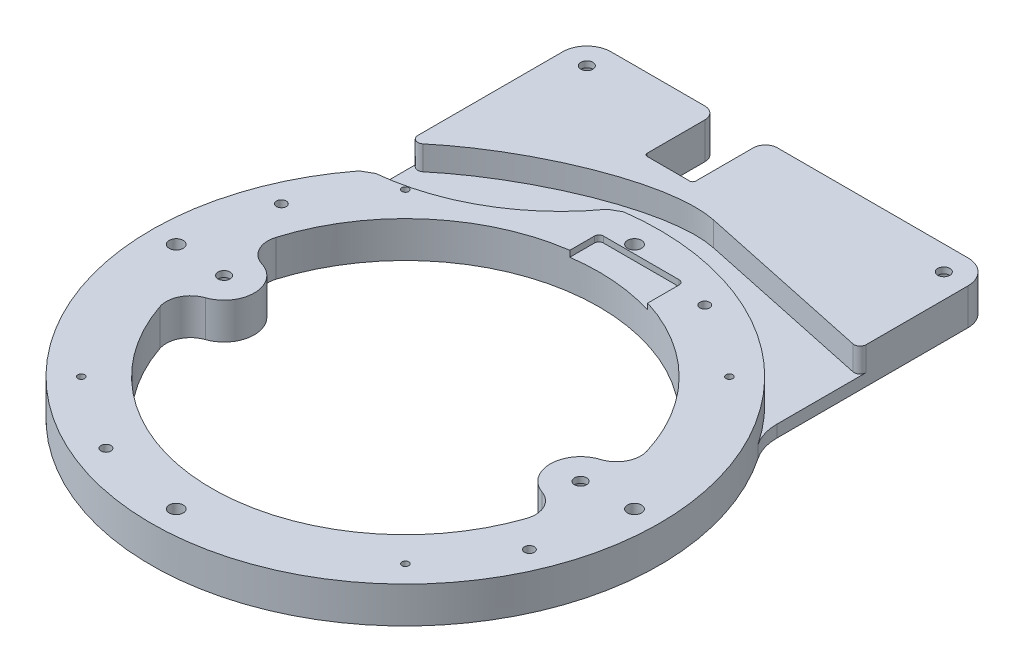
from build123d import *

# Parameters (mm, degrees)
SKETCH1_R           = 133.35
BOSS_EXTRUDE1_DEPTH = 19.05
SKETCH2_R           = 3.6703
SKETCH2_R_2         = 2.5781
SKETCH2_R_3         = 1.7859375
CUT_EXTRUDE1_DEPTH  = 20.05
BOSS_EXTRUDE2_DEPTH = 19.05
FILLET1_R           = 25.4
SKETCH4_R           = 3.175
CUT_EXTRUDE2_DEPTH  = 20.05
SKETCH5_R           = 7.9375
CUT_EXTRUDE3_DEPTH  = 15.875
CUT_EXTRUDE4_DEPTH  = 20.05
CUT_EXTRUDE5_DEPTH  = 12.7
FILLET2_R           = 3.175
CUT_EXTRUDE6_DEPTH  = 3.175


with BuildPart() as part:
    # Sketch1 → Boss-Extrude1 (new body)
    with BuildSketch(Plane(origin=(0, 0, 0), x_dir=(1, 0, 0), z_dir=(0, 1, 0))):
        Circle(SKETCH1_R)
    extrude(amount=BOSS_EXTRUDE1_DEPTH)

    # Sketch2 → Cut-Extrude1 (cut, through all)
    with BuildSketch(Plane(origin=(0, 19.05, 0), x_dir=(1, 0, 0), z_dir=(0, 1, 0))):
        with Locations((-120.2563, 0)):
            Circle(SKETCH2_R)
        with Locations((-111.10233558, 46.02009338)):
            Circle(SKETCH2_R_2)
        with Locations((120.2563, 0)):
            Circle(SKETCH2_R)
        with Locations((0, -120.2563)):
            Circle(SKETCH2_R)
        with Locations((0, 120.2563)):
            Circle(SKETCH2_R)
        with Locations((111.10233558, -46.02009338)):
            Circle(SKETCH2_R_2)
        with Locations((-46.02009338, -111.10233558)):
            Circle(SKETCH2_R_2)
        with Locations((46.02009338, 111.10233558)):
            Circle(SKETCH2_R_2)
        with Locations((-85.03404521, -85.03404521)):
            Circle(SKETCH2_R_3)
        with Locations((85.03404521, 85.03404521)):
            Circle(SKETCH2_R_3)
        with Locations((-85.03404521, 85.03404521)):
            Circle(SKETCH2_R_3)
        with Locations((85.03404521, -85.03404521)):
            Circle(SKETCH2_R_3)
    extrude(amount=-CUT_EXTRUDE1_DEPTH, mode=Mode.SUBTRACT)

    # Sketch3 → Boss-Extrude2 (add)
    with BuildSketch(Plane(origin=(0, 19.05, 0), x_dir=(1, 0, 0), z_dir=(0, 1, 0))):
        with BuildLine():
            Line((-106.3625, 80.431592635), (-106.3625, 188.9125))
            ThreePointArc((-106.3625, 188.9125), (-102.642756121, 197.892756121), (-93.6625, 201.6125))
            Line((-93.6625, 201.6125), (93.6625, 201.6125))
            ThreePointArc((93.6625, 201.6125), (102.642756121, 197.892756121), (106.3625, 188.9125))
            Line((106.3625, 188.9125), (106.3625, 80.431592635))
            ThreePointArc((106.3625, 80.431592635), (0, 133.35), (-106.3625, 80.431592635))
        make_face()
    extrude(amount=-BOSS_EXTRUDE2_DEPTH)

    # Fillet1
    fillet1_edges = [part.edges().sort_by_distance(p)[0] for p in [
        (106.3625, 9.525, -80.431592635),
        (-106.3625, 9.525, -80.431592635),
    ]]
    fillet(fillet1_edges, radius=FILLET1_R)

    # Sketch4 → Cut-Extrude2 (cut, through all)
    with BuildSketch(Plane(origin=(0, 19.05, 0), x_dir=(1, 0, 0), z_dir=(0, 1, 0))):
        with Locations((-93.6625, 188.9125)):
            Circle(SKETCH4_R)
        with Locations((93.6625, 188.9125)):
            Circle(SKETCH4_R)
        with Locations((93.5355, -1.5875)):
            Circle(SKETCH4_R)
        with Locations((-93.5355, -1.5875)):
            Circle(SKETCH4_R)
        with BuildLine():
            Line((-38.1, 165.1), (-38.1, 195.2625))
            ThreePointArc((-38.1, 195.2625), (-39.959871939, 199.752628061), (-44.45, 201.6125))
            Line((-44.45, 201.6125), (-6.35, 201.6125))
            ThreePointArc((-6.35, 201.6125), (-10.840128061, 199.752628061), (-12.7, 195.2625))
            Line((-12.7, 195.2625), (-12.7, 165.1))
            ThreePointArc((-12.7, 165.1), (-13.164967985, 163.977467985), (-14.2875, 163.5125))
            Line((-14.2875, 163.5125), (-36.5125, 163.5125))
            ThreePointArc((-36.5125, 163.5125), (-37.635032015, 163.977467985), (-38.1, 165.1))
        make_face()
    extrude(amount=-CUT_EXTRUDE2_DEPTH, mode=Mode.SUBTRACT)

    # Sketch5 → Cut-Extrude3 (cut)
    with BuildSketch(Plane.XZ):
        with Locations((-93.5355, 1.5875)):
            Circle(SKETCH5_R)
        with Locations((-93.6625, -188.9125)):
            Circle(SKETCH5_R)
        with Locations((93.6625, -188.9125)):
            Circle(SKETCH5_R)
        with Locations((93.5355, 1.5875)):
            Circle(SKETCH5_R)
    extrude(amount=-CUT_EXTRUDE3_DEPTH, mode=Mode.SUBTRACT)

    # Sketch6 → Cut-Extrude4 (cut, through all)
    with BuildSketch(Plane.XZ):
        with BuildLine():
            ThreePointArc((-97.25707655, -29.387430322), (0, -101.6), (97.25707655, -29.387430322))
            ThreePointArc((97.25707655, -29.387430322), (96.312482934, -19.750032603), (88.849078878, -13.580000851))
            ThreePointArc((88.849078878, -13.580000851), (77.662785938, 1.318105668), (88.337075578, 16.587233615))
            ThreePointArc((88.337075578, 16.587233615), (95.586803849, 23.006979086), (96.203812617, 32.67088058))
            ThreePointArc((96.203812617, 32.67088058), (0, 101.6), (-96.203812617, 32.67088058))
            ThreePointArc((-96.203812617, 32.67088058), (-95.586803849, 23.006979086), (-88.337075578, 16.587233615))
            ThreePointArc((-88.337075578, 16.587233615), (-77.662785938, 1.318105668), (-88.849078878, -13.580000851))
            ThreePointArc((-88.849078878, -13.580000851), (-96.312482934, -19.750032603), (-97.25707655, -29.387430322))
        make_face()
    extrude(amount=-CUT_EXTRUDE4_DEPTH, mode=Mode.SUBTRACT)

    # Sketch7 → Cut-Extrude5 (cut)
    with BuildSketch(Plane(origin=(0, 19.05, 0), x_dir=(1, 0, 0), z_dir=(0, 1, 0))):
        with BuildLine():
            Line((106.3625, 131.527748149), (9.586053414, 152.098216886))
            add(Edge.make_bspline(
                [(9.586053414, 152.098216886), (-20.233717631, 158.436604889), (-75.860757578, 134.149121206), (-106.3625, 105.832753729)],
                knots=[0, 0, 0, 0, 1, 1, 1, 1], degree=3))
            Line((-106.3625, 105.832753729), (-110.6805, 74.377748149))
            ThreePointArc((-110.6805, 74.377748149), (-108.217560682, 77.917790395), (-105.641439401, 81.376340427))
            Line((-105.641439401, 81.376340427), (-100.142178087, 84.551340427))
            ThreePointArc((-100.142178087, 84.551340427), (-56.884848889, 98.527448456), (-23.15251969, 129.001340427))
            Line((-23.15251969, 129.001340427), (-17.653258376, 132.176340427))
            ThreePointArc((-17.653258376, 132.176340427), (54.760261489, 121.58756623), (110.6805, 74.377748149))
            Line((110.6805, 74.377748149), (106.3625, 131.527748149))
        make_face()
    extrude(amount=-CUT_EXTRUDE5_DEPTH, mode=Mode.SUBTRACT)

    # Fillet2
    fillet2_edges = [part.edges().sort_by_distance(p)[0] for p in [
        (-106.3625, 12.7, -105.832753729),
        (106.3625, 12.7, -131.527748149),
    ]]
    fillet(fillet2_edges, radius=FILLET2_R)

    # Sketch8 → Cut-Extrude6 (cut)
    with BuildSketch(Plane(origin=(0, 19.05, 0), x_dir=(1, 0, 0), z_dir=(0, 1, 0))):
        with BuildLine():
            Line((27.78125, 115.8875), (-11.90625, 115.8875))
            ThreePointArc((-11.90625, 115.8875), (-13.590048023, 115.190048023), (-14.2875, 113.50625))
            Line((-14.2875, 113.50625), (-14.2875, 84.1375))
            Line((-14.2875, 84.1375), (30.1625, 84.1375))
            Line((30.1625, 84.1375), (30.1625, 113.50625))
            ThreePointArc((30.1625, 113.50625), (29.465048023, 115.190048023), (27.78125, 115.8875))
        make_face()
    extrude(amount=-CUT_EXTRUDE6_DEPTH, mode=Mode.SUBTRACT)


solid = part.part
